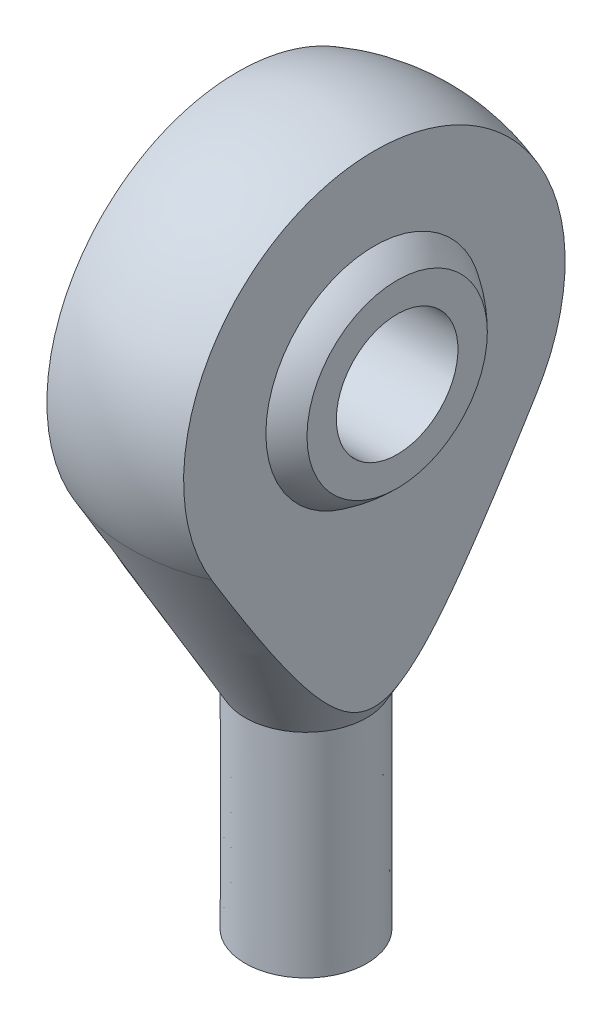
from build123d import *

# Parameters (mm, degrees)
WYTNIJ_WYCI_GNI_CIE1_DEPTH      = 10.998876849
WYTNIJ_WYCI_GNI_CIE1_DEPTH_BACK = 10.998876849
SZKIC4_W                        = 1.45
SZKIC4_H                        = 9
SZKIC8_R                        = 3
WYTNIJ_WYCI_GNI_CIE3_DEPTH      = 5.5
WYTNIJ_WYCI_GNI_CIE3_DEPTH_BACK = 5.5
SKETCH2_W                       = 18.954630749
SKETCH2_H                       = 12.318293367
CUT_EXTRUDE2_DEPTH              = 5.5
CUT_EXTRUDE2_DEPTH_BACK         = 5.5


with BuildPart() as part:
    # Szkic1 one side → Obrót4 (revolve)
    with BuildSketch(Plane.XY):
        with BuildLine():
            Line((-3, 21), (-3, 0))
            Line((-3, 0), (0, 0))
            Line((0, 0), (0.005166955, 46))
            ThreePointArc((0.005166955, 46), (-8.632770826, 41.038455208), (-8.699205566, 31.077206177))
            Line((-8.699205566, 31.077206177), (-3, 21))
        make_face()
    revolve(axis=Axis((0.005166955, 46, 0), (-0.000112325, -0.999999994, 0)))

    # Szkic2 → Wytnij-wyciągnięcie1 (cut, two sides)
    with BuildSketch(Plane.XY) as wytnij_wyci_gni_cie1_sk:
        Polygon((-3.375, 46), (-20, 46), (-20, 10.866665268), (-3.375, 21.663066505), align=None)
        Polygon((20, 46), (3.375, 46), (3.375, 21.65370739), (20, 10.857306153), align=None)
    extrude(amount=WYTNIJ_WYCI_GNI_CIE1_DEPTH, mode=Mode.SUBTRACT)
    extrude(wytnij_wyci_gni_cie1_sk.sketch, amount=-WYTNIJ_WYCI_GNI_CIE1_DEPTH_BACK, mode=Mode.SUBTRACT)

    # Szkic4 → Obrót5 (revolve)
    with BuildSketch(Plane.YX):
        with BuildLine():
            Line((40.449326049, 4.5), (40.449326049, -4.5))
            ThreePointArc((40.449326049, -4.5), (41.839498769, -2.438212993), (42.328030498, 0))
            ThreePointArc((42.328030498, 0), (41.839498769, 2.438212993), (40.449326049, 4.5))
        make_face()
        with Locations((39.724326049, 0)):
            Rectangle(SZKIC4_W, SZKIC4_H)
    revolve(axis=Axis((-0.999999975, 35.999326049, 0), (1, 0, 0)))

    # Szkic8 → Wytnij-wyciągnięcie3 (cut, two sides)
    with BuildSketch(Plane(origin=(0, 0, 0), x_dir=(0, 0, -1), z_dir=(1, 0, 0))) as wytnij_wyci_gni_cie3_sk:
        with Locations((0, 35.999326049)):
            Circle(SZKIC8_R)
    extrude(amount=WYTNIJ_WYCI_GNI_CIE3_DEPTH, mode=Mode.SUBTRACT)
    extrude(wytnij_wyci_gni_cie3_sk.sketch, amount=-WYTNIJ_WYCI_GNI_CIE3_DEPTH_BACK, mode=Mode.SUBTRACT)

    # Sketch2 → Cut-Extrude2 (cut, two sides)
    with BuildSketch(Plane(origin=(0, 0, 0), x_dir=(0, 0, -1), z_dir=(1, 0, 0))) as cut_extrude2_sk:
        with Locations((0.852276563, 4.340516208)):
            Rectangle(SKETCH2_W, SKETCH2_H)
    extrude(amount=CUT_EXTRUDE2_DEPTH, mode=Mode.SUBTRACT)
    extrude(cut_extrude2_sk.sketch, amount=-CUT_EXTRUDE2_DEPTH_BACK, mode=Mode.SUBTRACT)


solid = part.part
